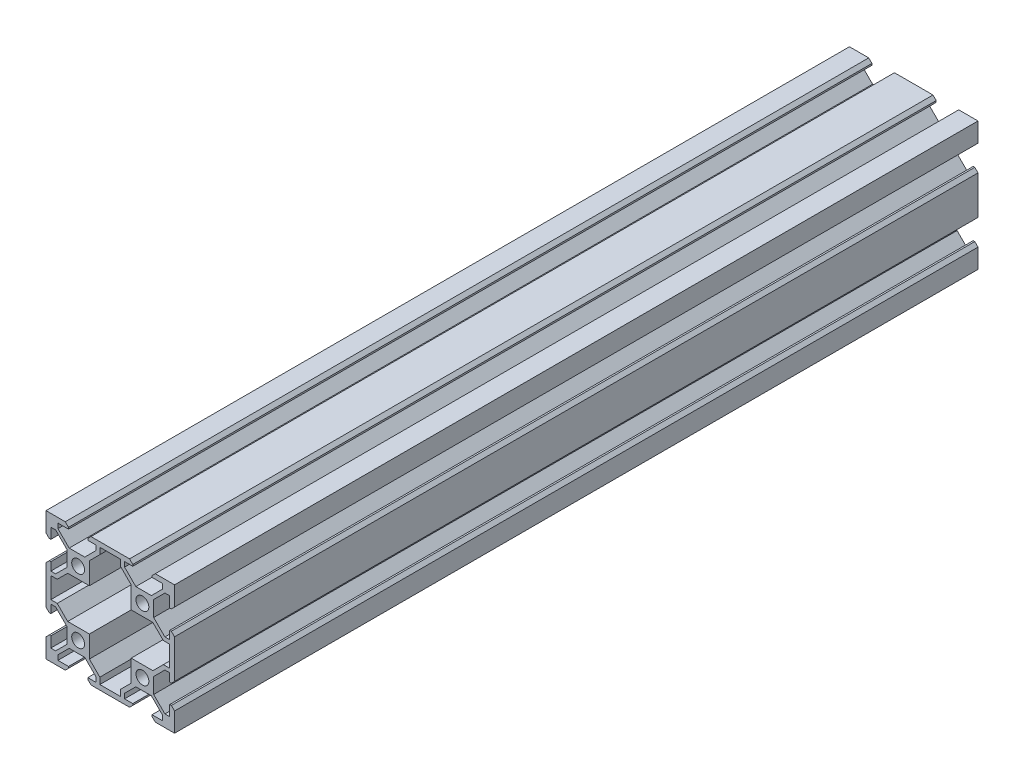
from build123d import *

# Parameters (mm, degrees)
BOSS_EXTRUDE1_DEPTH      = 125
BOSS_EXTRUDE1_DEPTH_BACK = 125


with BuildPart() as part:
    # Sketch1 → Boss-Extrude1 (new, two sides: drawn at the far end of the back side and taken through both)
    with BuildSketch(Plane(origin=(0, 0, 0), x_dir=(0, 1, 0), z_dir=(0, 0, 1)).offset(-BOSS_EXTRUDE1_DEPTH_BACK)):
        Polygon((-13, 19), (-14, 20), (-20, 20), (-20, 14), (-19, 13), (-18.5, 13), (-18.5, 16.292893219), (-17, 16.292893219), (-13.5, 12.792893219), (-13.5, 7.95), (-17, 4.45), (-18.5, 4.45), (-18.5, 7), (-19, 7), (-20, 6), (-20, -6), (-19, -7), (-18.5, -7), (-18.5, -4.45), (-17, -4.45), (-13.5, -7.95), (-13.5, -12.792893219), (-17, -16.292893219), (-18.5, -16.292893219), (-18.5, -13), (-19, -13), (-20, -14), (-20, -20), (-14, -20), (-13, -19), (-13, -18.5), (-16.292893219, -18.5), (-16.292893219, -17), (-12.792893219, -13.5), (-7.95, -13.5), (-4.45, -17), (-4.45, -18.5), (-7, -18.5), (-7, -19), (-6, -20), (6, -20), (7, -19), (7, -18.5), (4.45, -18.5), (4.45, -17), (7.95, -13.5), (12.792893219, -13.5), (16.292893219, -17), (16.292893219, -18.5), (13, -18.5), (13, -19), (14, -20), (20, -20), (20, -14), (19, -13), (18.5, -13), (18.5, -16.292893219), (17, -16.292893219), (13.5, -12.792893219), (13.5, -7.95), (17, -4.45), (18.5, -4.45), (18.5, -7), (19, -7), (20, -6), (20, 6), (19, 7), (18.5, 7), (18.5, 4.45), (17, 4.45), (13.5, 7.95), (13.5, 12.792893219), (17, 16.292893219), (18.5, 16.292893219), (18.5, 13), (19, 13), (20, 14), (20, 20), (14, 20), (13, 19), (13, 18.5), (16.292893219, 18.5), (16.292893219, 17), (12.792893219, 13.5), (7.95, 13.5), (4.45, 17), (4.45, 18.5), (7, 18.5), (7, 19), (6, 20), (-6, 20), (-7, 19), (-7, 18.5), (-4.45, 18.5), (-4.45, 17), (-7.95, 13.5), (-12.792893219, 13.5), (-16.292893219, 17), (-16.292893219, 18.5), (-13, 18.5), align=None)
        with BuildLine():
            ThreePointArc((-11.414213562, -11.414213562), (-11.414213562, -8.585786438), (-8.585786438, -8.585786438))
            ThreePointArc((-8.585786438, -8.585786438), (-8.585786438, -11.414213562), (-11.414213562, -11.414213562))
        make_face(mode=Mode.SUBTRACT)
        with BuildLine():
            ThreePointArc((11.414213562, -11.414213562), (8.585786438, -11.414213562), (8.585786438, -8.585786438))
            ThreePointArc((8.585786438, -8.585786438), (11.414213562, -8.585786438), (11.414213562, -11.414213562))
        make_face(mode=Mode.SUBTRACT)
        with BuildLine():
            ThreePointArc((-11.414213562, 11.414213562), (-8.585786438, 11.414213562), (-8.585786438, 8.585786438))
            ThreePointArc((-8.585786438, 8.585786438), (-11.414213562, 8.585786438), (-11.414213562, 11.414213562))
        make_face(mode=Mode.SUBTRACT)
        Polygon((3.25, 18.5), (3.25, 16.502943725), (6.5, 13.252943725), (6.5, 6.5), (13.252943725, 6.5), (16.502943725, 3.25), (18.5, 3.25), (18.5, -3.25), (16.502943725, -3.25), (13.252943725, -6.5), (6.5, -6.5), (6.5, -13.252943725), (3.25, -16.502943725), (3.25, -18.5), (-3.25, -18.5), (-3.25, -16.502943725), (-6.5, -13.252943725), (-6.5, -6.5), (-13.252943725, -6.5), (-16.502943725, -3.25), (-18.5, -3.25), (-18.5, 3.25), (-16.502943725, 3.25), (-13.252943725, 6.5), (-6.5, 6.5), (-6.5, 13.252943725), (-3.25, 16.502943725), (-3.25, 18.5), align=None, mode=Mode.SUBTRACT)
        with BuildLine():
            ThreePointArc((11.414213562, 11.414213562), (11.414213562, 8.585786438), (8.585786438, 8.585786438))
            ThreePointArc((8.585786438, 8.585786438), (8.585786438, 11.414213562), (11.414213562, 11.414213562))
        make_face(mode=Mode.SUBTRACT)
    extrude(amount=BOSS_EXTRUDE1_DEPTH + BOSS_EXTRUDE1_DEPTH_BACK)


solid = part.part
